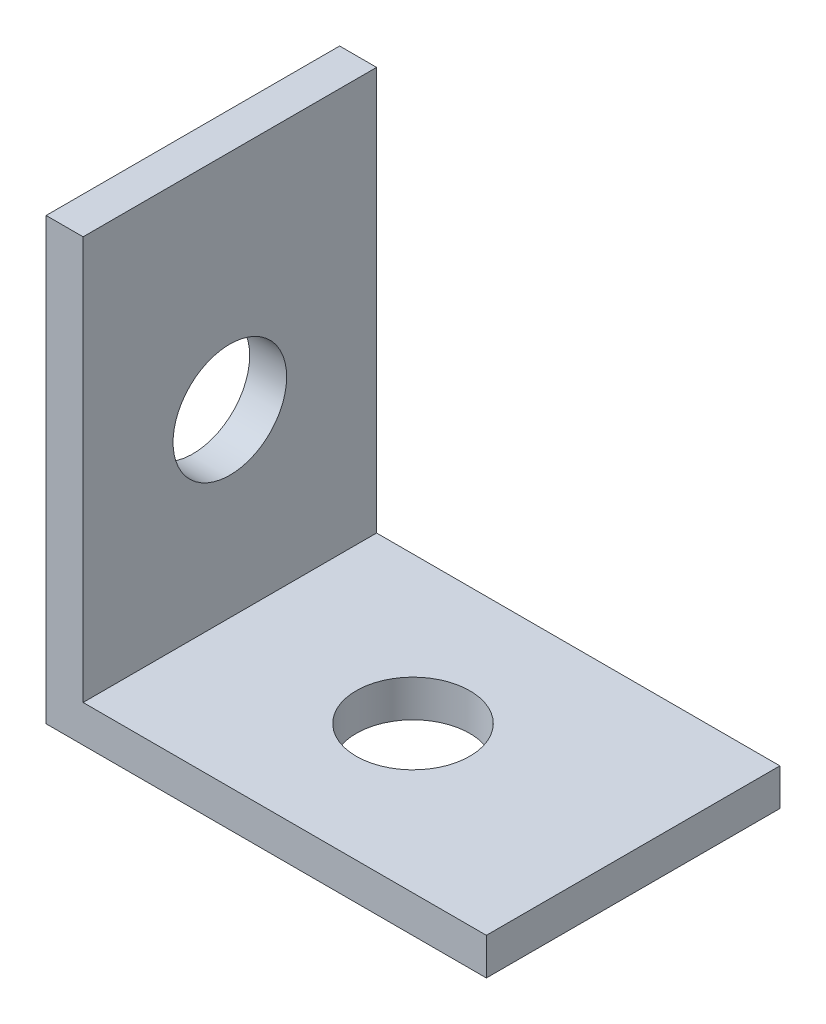
from build123d import *

# Parameters (mm, degrees)
BOSS_EXTRUDE1_DEPTH   = 12.7
F_8_CLEARANCE_HOLE1_D = 4.9149
F_8_CLEARANCE_HOLE2_D = 4.9149


with BuildPart() as part:
    # Sketch1 → Boss-Extrude1 (new body)
    with BuildSketch(Plane.XY):
        Polygon((-3.452609544, 16.036650639), (-3.452609544, -3.013349361), (15.597390456, -3.013349361), (15.597390456, -1.413149361), (-1.852409544, -1.413149361), (-1.852409544, 16.036650639), align=None)
    extrude(amount=BOSS_EXTRUDE1_DEPTH)

    # #8 Clearance Hole1 (through all)
    with Locations(Plane(origin=(0, -1.413149361, 0), x_dir=(1, 0, 0), z_dir=(0, 1, 0))):
        with Locations((6.072390456, -6.35)):
            Hole(F_8_CLEARANCE_HOLE1_D / 2)

    # #8 Clearance Hole2 (through all)
    with Locations(Plane(origin=(-1.852409544, 0, 0), x_dir=(0, 0, -1), z_dir=(1, 0, 0))):
        with Locations((-6.35, 6.384650639)):
            Hole(F_8_CLEARANCE_HOLE2_D / 2)


solid = part.part
